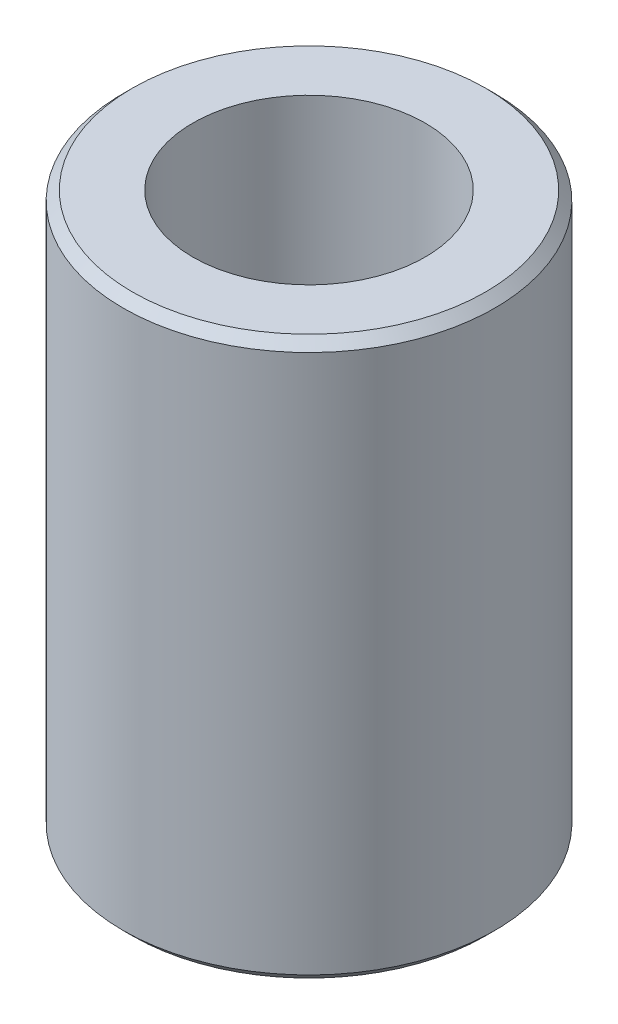
from build123d import *

# Parameters (mm, degrees)
SKETCH1_R           = 20
SKETCH1_R_2         = 12.5
BOSS_EXTRUDE1_DEPTH = 60
CHAMFER1_SIZE       = 1


with BuildPart() as part:
    # Sketch1 → Boss-Extrude1 (new body)
    with BuildSketch(Plane(origin=(0, 0, 0), x_dir=(1, 0, 0), z_dir=(0, 1, 0))):
        Circle(SKETCH1_R)
        Circle(SKETCH1_R_2, mode=Mode.SUBTRACT)
    extrude(amount=BOSS_EXTRUDE1_DEPTH)

    # Chamfer1
    chamfer1_edges = [part.edges().sort_by_distance(p)[0] for p in [
        (-20, 0, 0),
        (-20, 60, 0),
    ]]
    chamfer(chamfer1_edges, length=CHAMFER1_SIZE)


solid = part.part
